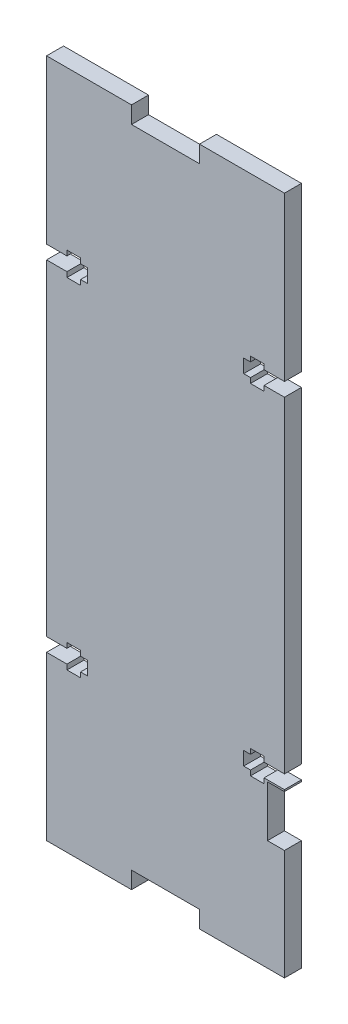
from build123d import *

# Parameters (mm, degrees)
BOSS_EXTRUDE1_DEPTH  = 5
CUT_EXTRUDE1_DEPTH   = 10
MIRROR2_COPY_1_DEPTH = 10
SKETCH4_W            = 5
SKETCH4_H            = 15
CUT_EXTRUDE2_DEPTH   = 10


with BuildPart() as part:
    # Sketch2 → Boss-Extrude1 (new body)
    with BuildSketch(Plane.XY):
        Polygon((-10, 100), (-35, 100), (-35, -100), (-10, -100), (-10, -95), (10, -95), (10, -100), (35, -100), (35, 100), (10, 100), (10, 95), (-10, 95), align=None)
    extrude(amount=BOSS_EXTRUDE1_DEPTH)

    # Sketch3 → Cut-Extrude1 (cut)
    with BuildSketch(Plane.XY.offset(5)):
        Polygon((35, -52), (29, -52), (29, -53.5), (25, -53.5), (25, -52), (23, -52), (23, -48), (25, -48), (25, -46.5), (29, -46.5), (29, -48), (35, -48), align=None)
    cut_extrude1 = extrude(amount=-CUT_EXTRUDE1_DEPTH, mode=Mode.SUBTRACT)

    # Mirror1: Cut-Extrude1 across plane
    add(cut_extrude1.mirror(Plane.ZX), mode=Mode.SUBTRACT)

    # Mirror2: Cut-Extrude1 across plane
    add(cut_extrude1.mirror(Plane(origin=(0, 0, 0), x_dir=(0, 0, 1), z_dir=(1, 0, 0))), mode=Mode.SUBTRACT)

    # Mirror2 copy 1 sketch → Mirror2 copy 1 (cut)
    with BuildSketch(Plane(origin=(0, 0, 5), x_dir=(-1, 0, 0), z_dir=(0, 0, 1))):
        Polygon((35, -52), (29, -52), (29, -53.5), (25, -53.5), (25, -52), (23, -52), (23, -48), (25, -48), (25, -46.5), (29, -46.5), (29, -48), (35, -48), align=None)
    extrude(amount=-MIRROR2_COPY_1_DEPTH, mode=Mode.SUBTRACT)

    # Sketch4 → Cut-Extrude2 (cut)
    with BuildSketch(Plane(origin=(0, 0, 0), x_dir=(-1, 0, 0), z_dir=(0, 0, -1))):
        with Locations((-32.5, -60)):
            Rectangle(SKETCH4_W, SKETCH4_H)
    extrude(amount=-CUT_EXTRUDE2_DEPTH, mode=Mode.SUBTRACT)


solid = part.part
